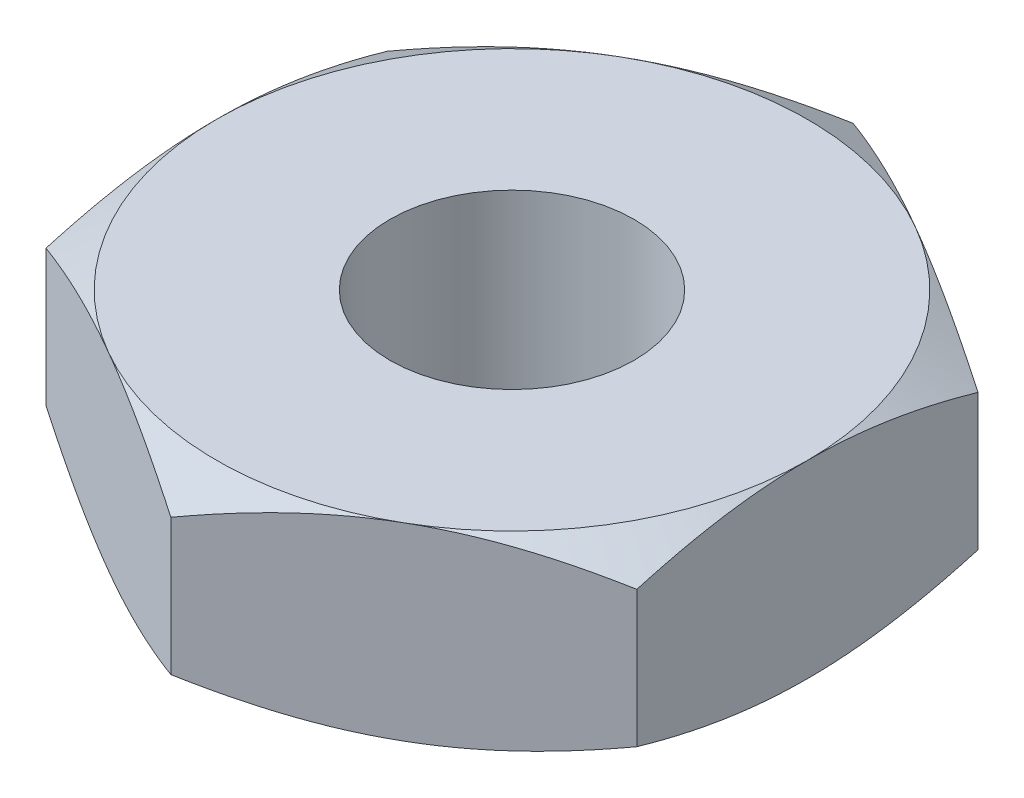
from build123d import *

# Parameters (mm, degrees)
EXTRUDE_1_DEPTH    = 1.6
SKETCH_4_R         = 1.0335
CUT_EXTRUDE1_DEPTH = 10


with BuildPart() as part:
    # 草图1 → 凸台-拉伸1 (new body)
    with BuildSketch(Plane(origin=(0, 0, 0), x_dir=(1, 0, 0), z_dir=(0, 1, 0))):
        Polygon((0, 2.886751346), (-2.5, 1.443375673), (-2.5, -1.443375673), (0, -2.886751346), (2.5, -1.443375673), (2.5, 1.443375673), align=None)
    extrude(amount=EXTRUDE_1_DEPTH)

    # 草图2 → 切除-旋转1 (revolve, cut)
    with BuildSketch(Plane(origin=(0, 0, 0), x_dir=(0, 0, -1), z_dir=(1, 0, 0))):
        Polygon((2.886751346, 1.6), (2.886751346, 1.376709006), (2.5, 1.6), align=None)
    revolve(axis=Axis((0, 0, 0), (0, 1, 0)), mode=Mode.SUBTRACT)

    # 草图3 → 切除-旋转2 (revolve, cut)
    with BuildSketch(Plane(origin=(0, 0, 0), x_dir=(0, 0, -1), z_dir=(1, 0, 0))):
        Polygon((2.886751346, 0), (2.886751346, 0.223290994), (2.5, 0), align=None)
    revolve(axis=Axis((0, 0, 0), (0, 1, 0)), mode=Mode.SUBTRACT)

    # 草图4 → Cut-Extrude1 (cut)
    with BuildSketch(Plane(origin=(0, 1.6, 0), x_dir=(1, 0, 0), z_dir=(0, 1, 0))):
        Circle(SKETCH_4_R)
    extrude(amount=-CUT_EXTRUDE1_DEPTH, mode=Mode.SUBTRACT)


solid = part.part
